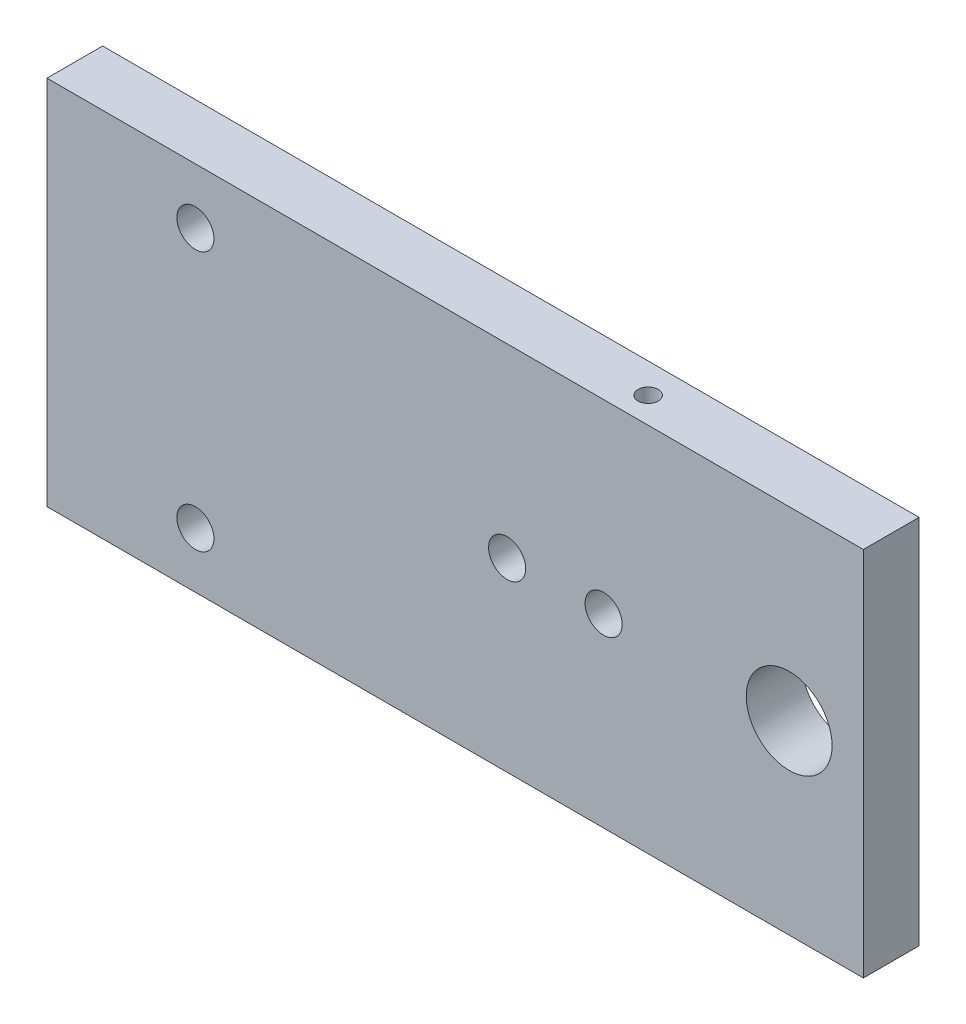
from build123d import *

# Parameters (mm, degrees)
SKETCH1_W                   = 139.7
SKETCH1_H                   = 63.5
BOSS_EXTRUDE1_DEPTH         = 9.525
F_5_8_18_TAPPED_HOLE1_D     = 14.68374
F_1_4_0_25_DIAMETER_HOLE1_D = 6.35
F_8_32_TAPPED_HOLE1_D       = 3.4544
F_8_32_TAPPED_HOLE1_DEPTH   = 12.7
F_8_32_TAPPED_HOLE1_TIP     = 1.037806461
SKETCH9_R                   = 3.175
CUT_EXTRUDE1_DEPTH          = 10.525


with BuildPart() as part:
    # Sketch1 → Boss-Extrude1 (new body)
    with BuildSketch(Plane.XY):
        with Locations((69.85, 31.75)):
            Rectangle(SKETCH1_W, SKETCH1_H)
    extrude(amount=BOSS_EXTRUDE1_DEPTH)

    # 5/8-18 Tapped Hole1 (through all)
    with Locations(Plane.XY.offset(9.525)):
        with Locations((127, 31.75)):
            Hole(F_5_8_18_TAPPED_HOLE1_D / 2)

    # 1/4 (0.25) Diameter Hole1 (through all)
    with Locations(Plane(origin=(25.4, 53.975, 9.525), x_dir=(1, 0, 0), z_dir=(0, 0, 1))):
        with Locations((0, 0), (0, -44.45)):
            Hole(F_1_4_0_25_DIAMETER_HOLE1_D / 2)

    # #8-32 Tapped Hole1
    with Locations(Plane(origin=(98.425, 63.5, 5.08), x_dir=(0, 0, 1), z_dir=(0, 1, 0))):
        with Locations((0, 0)):
            Hole(F_8_32_TAPPED_HOLE1_D / 2, depth=F_8_32_TAPPED_HOLE1_DEPTH)
            with Locations((0, 0, -(F_8_32_TAPPED_HOLE1_DEPTH + F_8_32_TAPPED_HOLE1_TIP / 2))):  # 118° drill point
                Cone(0, F_8_32_TAPPED_HOLE1_D / 2, F_8_32_TAPPED_HOLE1_TIP, mode=Mode.SUBTRACT)

    # Sketch9 → Cut-Extrude1 (cut, through all)
    with BuildSketch(Plane.XY.offset(9.525)):
        with Locations((95.25, 31.75)):
            Circle(SKETCH9_R)
        with Locations((78.74, 31.75)):
            Circle(SKETCH9_R)
    extrude(amount=-CUT_EXTRUDE1_DEPTH, mode=Mode.SUBTRACT)


solid = part.part
